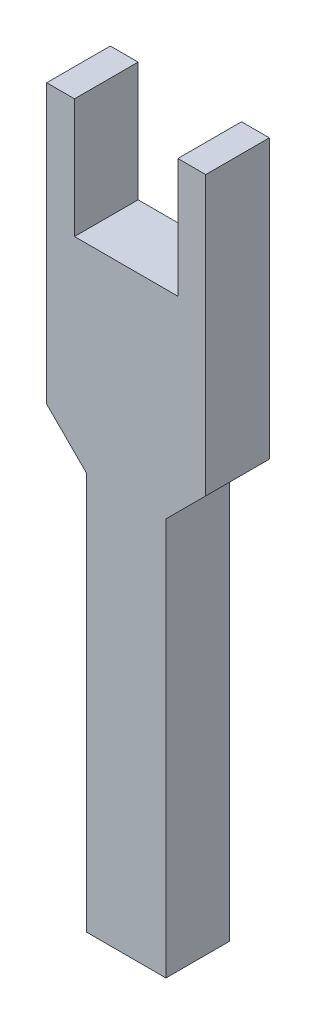
from build123d import *

# Parameters (mm, degrees)
CROQUIS1_W              = 20
CROQUIS1_H              = 40
SALIENTE_EXTRUIR1_DEPTH = 8
CROQUIS2_W              = 13
CROQUIS2_H              = 15
CORTAR_EXTRUIR1_DEPTH   = 8
CHAFL_N3_SIZE           = 5
CHAFL_N4_SIZE           = 5
CROQUIS4_W              = 10
CROQUIS4_H              = 8
SALIENTE_EXTRUIR2_DEPTH = 50


with BuildPart() as part:
    # Croquis1 → Saliente-Extruir1 (new body)
    with BuildSketch(Plane.XY):
        Rectangle(CROQUIS1_W, CROQUIS1_H)
    extrude(amount=SALIENTE_EXTRUIR1_DEPTH)

    # Croquis2 → Cortar-Extruir1 (cut)
    with BuildSketch(Plane(origin=(0, 0, 0), x_dir=(-1, 0, 0), z_dir=(0, 0, -1))):
        with Locations((0, 12.5)):
            Rectangle(CROQUIS2_W, CROQUIS2_H)
    extrude(amount=-CORTAR_EXTRUIR1_DEPTH, mode=Mode.SUBTRACT)

    # Chaflán3
    chafl_n3_edges = [part.edges().sort_by_distance(p)[0] for p in [
        (-10, -20, 4),
    ]]
    chamfer(chafl_n3_edges, length=CHAFL_N3_SIZE)

    # Chaflán4
    chafl_n4_edges = [part.edges().sort_by_distance(p)[0] for p in [
        (10, -20, 4),
    ]]
    chamfer(chafl_n4_edges, length=CHAFL_N4_SIZE)

    # Croquis4 → Saliente-Extruir2 (add)
    with BuildSketch(Plane.XZ.offset(20)):
        with Locations((0, 4)):
            Rectangle(CROQUIS4_W, CROQUIS4_H)
    extrude(amount=SALIENTE_EXTRUIR2_DEPTH)


solid = part.part
